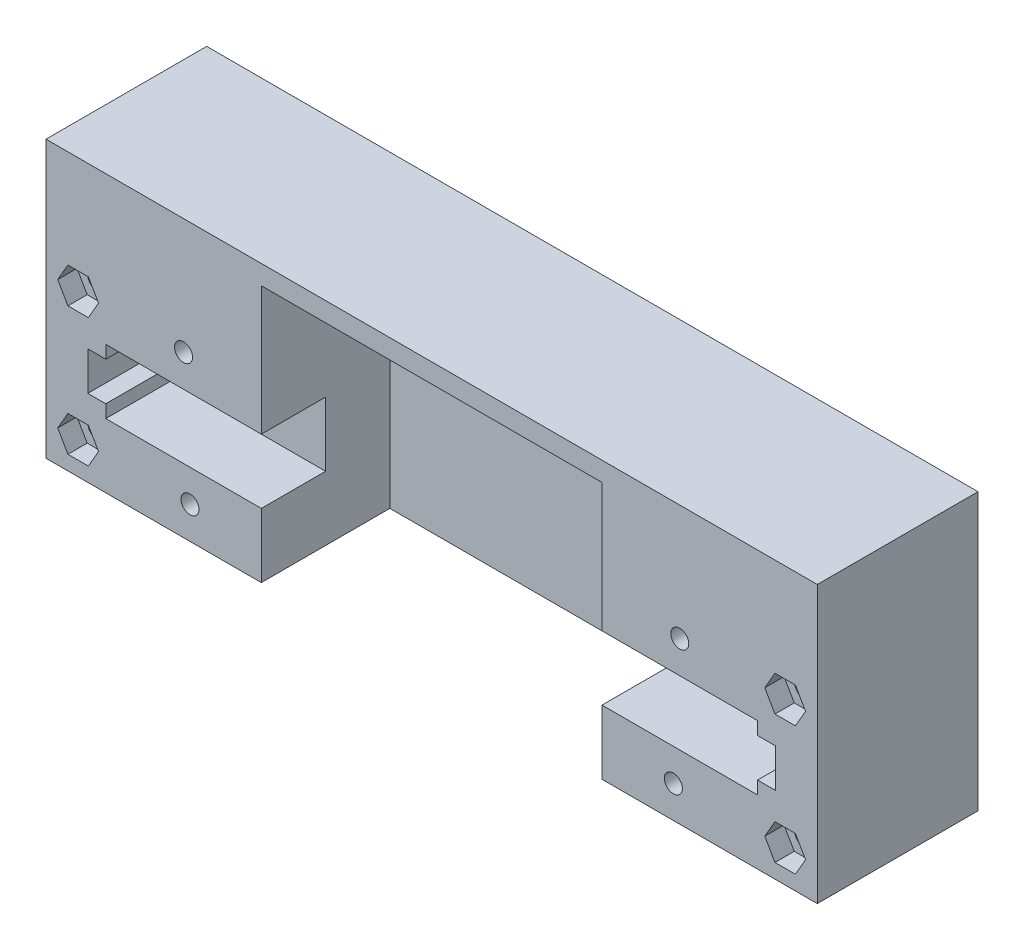
from build123d import *

# Parameters (mm, degrees)
ESQUISSE1_W             = 120
ESQUISSE1_H             = 30
ESQUISSE1_R             = 1.5
BOSS_EXTRU_1_DEPTH      = 5
BOSS_EXTRU_2_DEPTH      = 20
BOSS_EXTRU_3_DEPTH      = 10
ESQUISSE1_6_R           = 1.5
BOSS_EXTRU_4_DEPTH      = 17
ESQUISSE2_R             = 1.4
ENL_V_MAT_EXTRU_1_DEPTH = 26
BOSS_EXTRU_5_DEPTH      = 10
ESQUISSE4_W             = 120
ESQUISSE4_H             = 25
BOSS_EXTRU_6_DEPTH      = 3


with BuildPart() as part:
    # Esquisse1 → Boss.-Extru.1 (new body)
    with BuildSketch(Plane.XY):
        Rectangle(ESQUISSE1_W, ESQUISSE1_H)
        with Locations((-55, 10)):
            Circle(ESQUISSE1_R, mode=Mode.SUBTRACT)
        with Locations((-55, -10)):
            Circle(ESQUISSE1_R, mode=Mode.SUBTRACT)
        with Locations((55, -10)):
            Circle(ESQUISSE1_R, mode=Mode.SUBTRACT)
        with Locations((55, 10)):
            Circle(ESQUISSE1_R, mode=Mode.SUBTRACT)
    extrude(amount=-BOSS_EXTRU_1_DEPTH)

    # Esquisse1_4 → Boss.-Extru.2 (add)
    with BuildSketch(Plane.XY):
        Polygon((-26.5, 15), (-60, 15), (-60, -15), (-26.5, -15), (-26.5, -5), (-50.7, -5), (-50.7, -3), (-53.5, -3), (-53.5, 3), (-50.7, 3), (-50.7, 5), (-26.5, 5), align=None)
        Polygon((-53.41228676, 12.75), (-51.824573519, 10), (-53.41228676, 7.25), (-56.58771324, 7.25), (-58.175426481, 10), (-56.58771324, 12.75), align=None, mode=Mode.SUBTRACT)
        Polygon((-53.41228676, -7.25), (-51.824573519, -10), (-53.41228676, -12.75), (-56.58771324, -12.75), (-58.175426481, -10), (-56.58771324, -7.25), align=None, mode=Mode.SUBTRACT)
        Polygon((60, 15), (26.5, 15), (26.5, 5), (50.7, 5), (50.7, 3), (53.5, 3), (53.5, -3), (50.7, -3), (50.7, -5), (26.5, -5), (26.5, -15), (60, -15), align=None)
        Polygon((56.58771324, 7.25), (53.41228676, 7.25), (51.824573519, 10), (53.41228676, 12.75), (56.58771324, 12.75), (58.175426481, 10), align=None, mode=Mode.SUBTRACT)
        Polygon((56.58771324, -7.25), (58.175426481, -10), (56.58771324, -12.75), (53.41228676, -12.75), (51.824573519, -10), (53.41228676, -7.25), align=None, mode=Mode.SUBTRACT)
    extrude(amount=BOSS_EXTRU_2_DEPTH)

    # Esquisse1_5 → Boss.-Extru.3 (add)
    with BuildSketch(Plane.XY):
        Polygon((-26.5, -5), (-26.5, 5), (-50.7, 5), (-50.7, 3), (-53.5, 3), (-53.5, -3), (-50.7, -3), (-50.7, -5), align=None)
        Polygon((50.7, 5), (26.5, 5), (26.5, -5), (50.7, -5), (50.7, -3), (53.5, -3), (53.5, 3), (50.7, 3), align=None)
    extrude(amount=BOSS_EXTRU_3_DEPTH)

    # Esquisse1_6 → Boss.-Extru.4 (add)
    with BuildSketch(Plane.XY):
        Polygon((51.824573519, 10), (53.41228676, 12.75), (56.58771324, 12.75), (58.175426481, 10), (56.58771324, 7.25), (53.41228676, 7.25), align=None)
        with Locations((55, 10)):
            Circle(ESQUISSE1_6_R, mode=Mode.SUBTRACT)
        Polygon((56.58771324, -7.25), (53.41228676, -7.25), (51.824573519, -10), (53.41228676, -12.75), (56.58771324, -12.75), (58.175426481, -10), align=None)
        with Locations((55, -10)):
            Circle(ESQUISSE1_6_R, mode=Mode.SUBTRACT)
        Polygon((-56.58771324, 7.25), (-53.41228676, 7.25), (-51.824573519, 10), (-53.41228676, 12.75), (-56.58771324, 12.75), (-58.175426481, 10), align=None)
        with Locations((-55, 10)):
            Circle(ESQUISSE1_6_R, mode=Mode.SUBTRACT)
        Polygon((-51.824573519, -10), (-53.41228676, -12.75), (-56.58771324, -12.75), (-58.175426481, -10), (-56.58771324, -7.25), (-53.41228676, -7.25), align=None)
        with Locations((-55, -10)):
            Circle(ESQUISSE1_6_R, mode=Mode.SUBTRACT)
    extrude(amount=BOSS_EXTRU_4_DEPTH)

    # Esquisse2 → Enlèv. mat.-Extru.1 (cut, through all)
    with BuildSketch(Plane.XY.offset(20)):
        with Locations((-38.6, 10)):
            Circle(ESQUISSE2_R)
        with Locations((-37.6, -10)):
            Circle(ESQUISSE2_R)
        with Locations((38.6, 10)):
            Circle(ESQUISSE2_R)
        with Locations((37.6, -10)):
            Circle(ESQUISSE2_R)
    extrude(amount=-ENL_V_MAT_EXTRU_1_DEPTH, mode=Mode.SUBTRACT)

    # Esquisse3 → Boss.-Extru.5 (add)
    with BuildSketch(Plane(origin=(0, 15, 0), x_dir=(1, 0, 0), z_dir=(0, 1, 0))):
        Polygon((-60, -20), (-60, 5), (60, 5), (60, -20), (26.5, -20), (26.5, 0), (-26.5, 0), (-26.5, -20), align=None)
    extrude(amount=BOSS_EXTRU_5_DEPTH)

    # Esquisse4 → Boss.-Extru.6 (add)
    with BuildSketch(Plane(origin=(0, 25, 0), x_dir=(1, 0, 0), z_dir=(0, 1, 0))):
        with Locations((0, -7.5)):
            Rectangle(ESQUISSE4_W, ESQUISSE4_H)
    extrude(amount=BOSS_EXTRU_6_DEPTH)


solid = part.part
